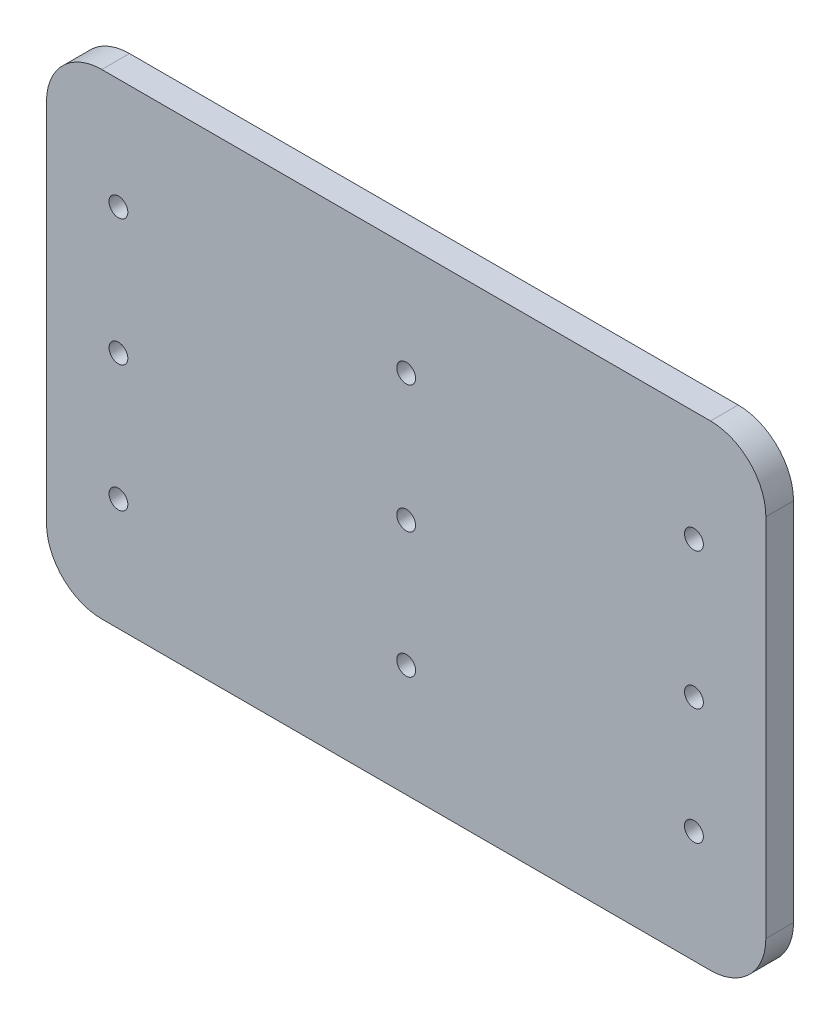
from build123d import *

# Parameters (mm, degrees)
SKETCH1_R           = 1.7
BOSS_EXTRUDE1_DEPTH = 5


with BuildPart() as part:
    # Sketch1 → Boss-Extrude1 (new body)
    with BuildSketch(Plane.XY):
        with BuildLine():
            Line((-55, 43), (55, 43))
            ThreePointArc((55, 43), (62.071067812, 40.071067812), (65, 33))
            Line((65, 33), (65, -33))
            ThreePointArc((65, -33), (62.071067812, -40.071067812), (55, -43))
            Line((55, -43), (-55, -43))
            ThreePointArc((-55, -43), (-62.071067812, -40.071067812), (-65, -33))
            Line((-65, -33), (-65, 33))
            ThreePointArc((-65, 33), (-62.071067812, 40.071067812), (-55, 43))
        make_face()
        with Locations((-52, 23)):
            Circle(SKETCH1_R, mode=Mode.SUBTRACT)
        with Locations((-52, -22.72)):
            Circle(SKETCH1_R, mode=Mode.SUBTRACT)
        with Locations((52, 23)):
            Circle(SKETCH1_R, mode=Mode.SUBTRACT)
        with Locations((52, -22.72)):
            Circle(SKETCH1_R, mode=Mode.SUBTRACT)
        with Locations((-52, 0.14)):
            Circle(SKETCH1_R, mode=Mode.SUBTRACT)
        Circle(SKETCH1_R, mode=Mode.SUBTRACT)
        with Locations((0, -22.72)):
            Circle(SKETCH1_R, mode=Mode.SUBTRACT)
        with Locations((0, 23)):
            Circle(SKETCH1_R, mode=Mode.SUBTRACT)
        with Locations((52, -1.7)):
            Circle(SKETCH1_R, mode=Mode.SUBTRACT)
    extrude(amount=BOSS_EXTRUDE1_DEPTH)


solid = part.part
